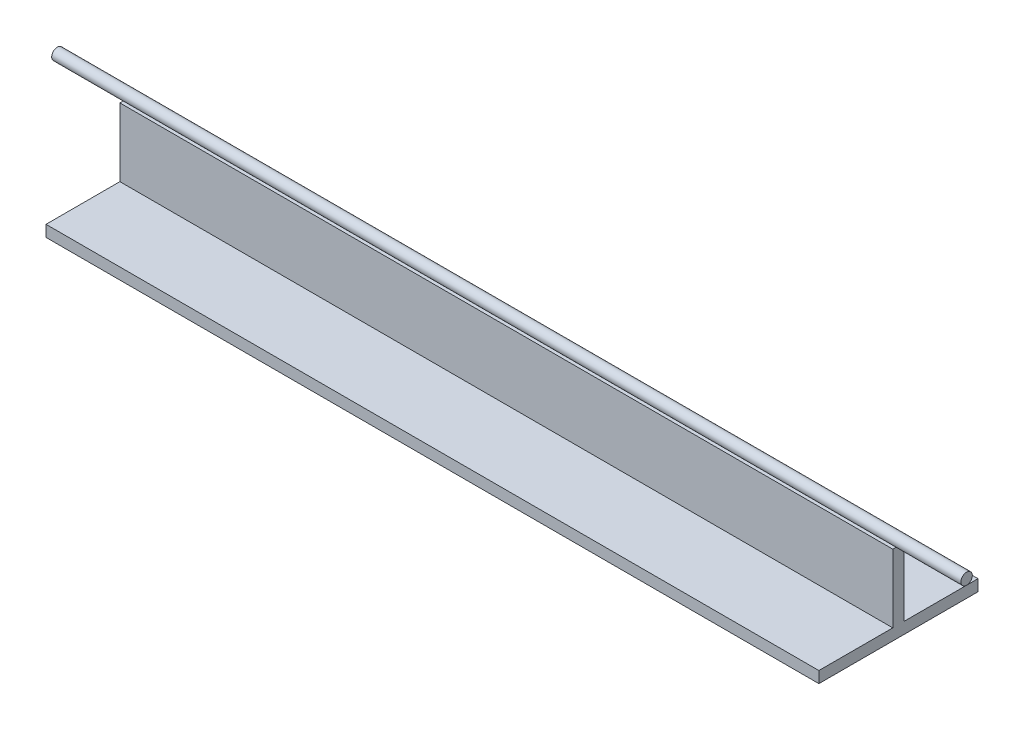
from build123d import *

# Parameters (mm, degrees)
SKETCH1_W                = 340
SKETCH1_H                = 5
BOSS_EXTRUDE1_DEPTH      = 30
SKETCH2_R                = 2.5
BOSS_EXTRUDE2_DEPTH      = 30
BOSS_EXTRUDE2_DEPTH_BACK = 370
SKETCH3_W                = 340
SKETCH3_H                = 70
BOSS_EXTRUDE3_DEPTH      = 5


with BuildPart() as part:
    # Sketch1 → Boss-Extrude1 (new body)
    with BuildSketch(Plane(origin=(0, 0, 0), x_dir=(1, 0, 0), z_dir=(0, 1, 0))):
        Rectangle(SKETCH1_W, SKETCH1_H)
    extrude(amount=BOSS_EXTRUDE1_DEPTH)

    # Sketch3 → Boss-Extrude3 (add)
    with BuildSketch(Plane.XZ):
        Rectangle(SKETCH3_W, SKETCH3_H)
    extrude(amount=BOSS_EXTRUDE3_DEPTH)


with BuildPart() as body_2:
    # Sketch2 → Boss-Extrude2 (new body, two sides)
    with BuildSketch(Plane(origin=(170, 0, 0), x_dir=(0, 0, -1), z_dir=(1, 0, 0))) as boss_extrude2_sk:
        with Locations((0, 32.5)):
            Circle(SKETCH2_R)
    extrude(amount=BOSS_EXTRUDE2_DEPTH)
    extrude(boss_extrude2_sk.sketch, amount=-BOSS_EXTRUDE2_DEPTH_BACK)


solid = Compound([part.part, body_2.part])
